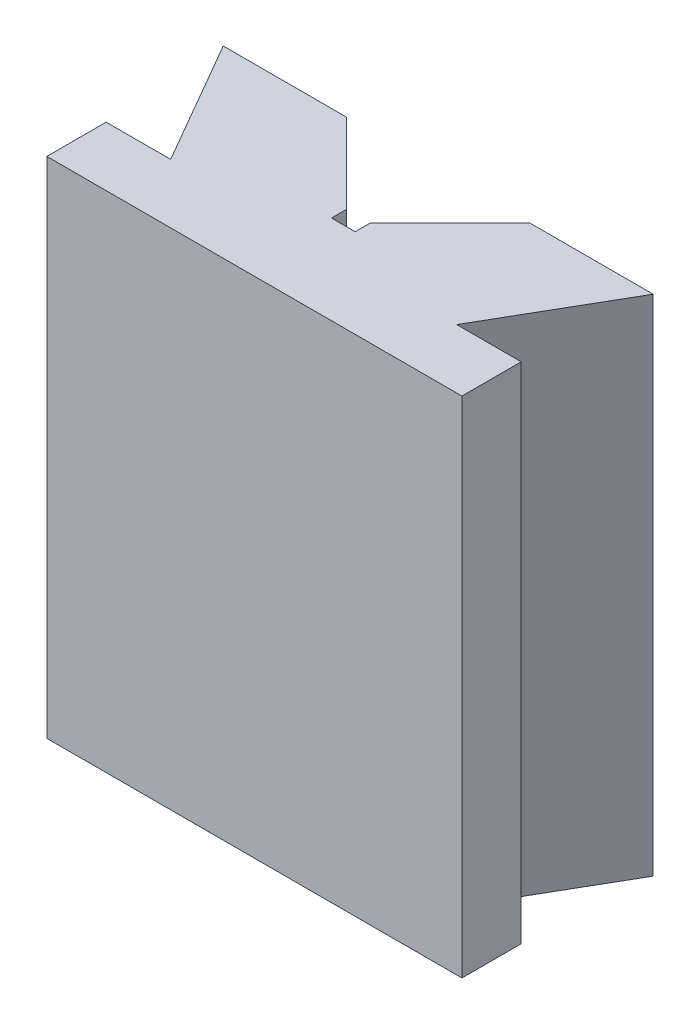
from build123d import *

# Parameters (mm, degrees)
P_IDAT_VYSUNUT_M1_DEPTH = 170


with BuildPart() as part:
    # Skica1 → Přidat vysunutím1 (new body)
    with BuildSketch(Plane(origin=(0, 0, 0), x_dir=(1, 0, 0), z_dir=(0, 1, 0))):
        Polygon((0, 0), (0, 20), (21.748711306, 20), (-2.5, 62), (39, 62), (66, 35), (66, 30), (74, 30), (74, 35), (101, 62), (142.5, 62), (118.251288694, 20), (140, 20), (140, 0), align=None)
    extrude(amount=P_IDAT_VYSUNUT_M1_DEPTH)


solid = part.part
